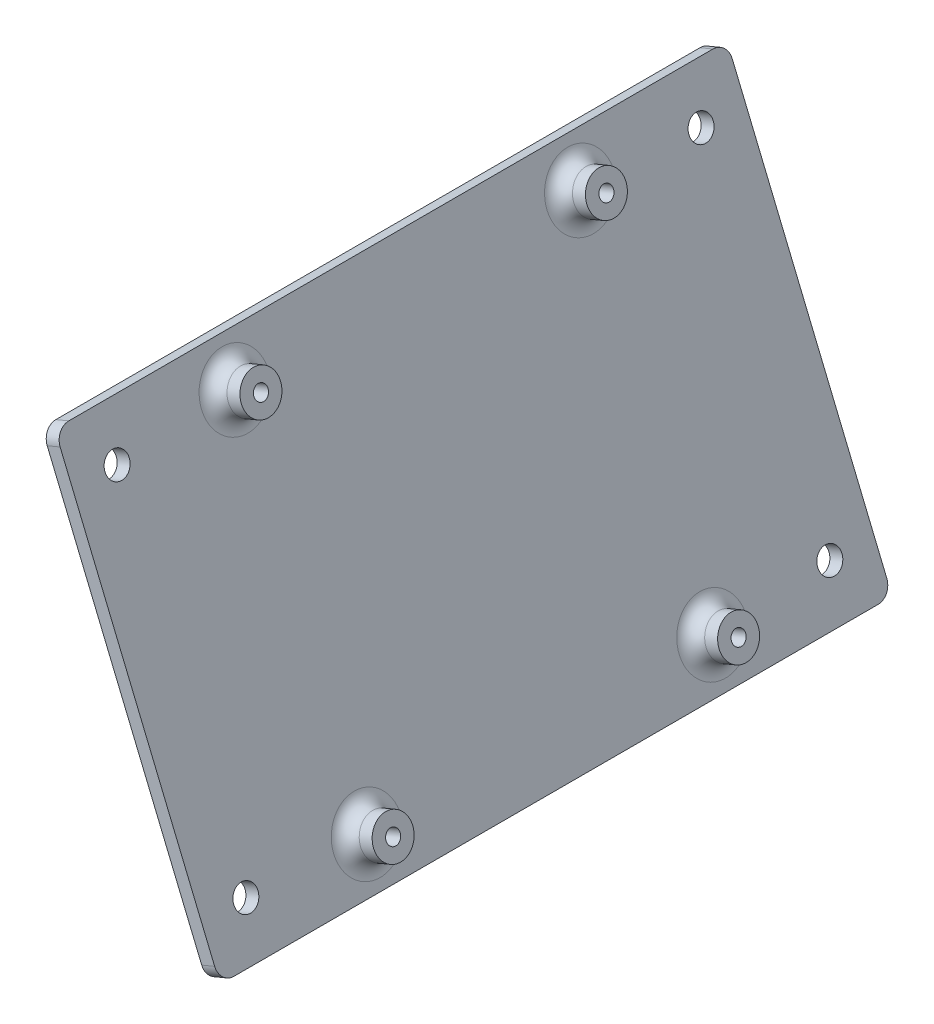
from build123d import *

# Parameters (mm, degrees)
SKETCH1_W           = 152.4
SKETCH1_H           = 97.79
BOSS_EXTRUDE1_DEPTH = 3.175
SKETCH2_R           = 4.445
BOSS_EXTRUDE2_DEPTH = 6.35
FILLET1_R           = 3.175
SKETCH4_R           = 1.6
CUT_EXTRUDE1_DEPTH  = 45.126339074
FILLET2_R           = 3.175
CUT_EXTRUDE2_DEPTH  = 38.776339074


with BuildPart() as part:
    # Sketch1 → Boss-Extrude1 (new body)
    with BuildSketch(Plane(origin=(-3845.744053595, -1594.742620069, 0), x_dir=(0, 0, -1), z_dir=(0.923728021, 0.383049008, 0))):
        with Locations((-2.512437172, -244.506793415)):
            Rectangle(SKETCH1_W, SKETCH1_H)
    extrude(amount=BOSS_EXTRUDE1_DEPTH)

    # Sketch2 → Boss-Extrude2 (add)
    with BuildSketch(Plane(origin=(-3842.811217127, -1593.526439469, 0), x_dir=(0, 0, -1), z_dir=(0.923728021, 0.383049008, 0))):
        with Locations((36.752562828, -283.626793415)):
            Circle(SKETCH2_R)
        with Locations((-41.577437172, -283.626793415)):
            Circle(SKETCH2_R)
        with Locations((-41.577437172, -205.386793415)):
            Circle(SKETCH2_R)
        with Locations((36.752562828, -205.386793415)):
            Circle(SKETCH2_R)
    extrude(amount=BOSS_EXTRUDE2_DEPTH)

    # Fillet1
    fillet1_edges = [part.edges().sort_by_distance(p)[0] for p in [
        (-3734.168255249, -1855.520456151, -32.307562828),
        (-3734.168255249, -1855.520456151, 46.022437172),
        (-3764.13800964, -1783.247975761, 46.022437172),
        (-3764.13800964, -1783.247975761, -32.307562828),
    ]]
    fillet(fillet1_edges, radius=FILLET1_R)

    # Sketch4 → Cut-Extrude1 (cut, through all)
    with BuildSketch(Plane(origin=(-3836.945544191, -1591.094078268, 0), x_dir=(0, 0, -1), z_dir=(0.923728021, 0.383049008, 0))):
        with Locations((36.752562828, -205.386793415)):
            Circle(SKETCH4_R)
        with Locations((-41.577437172, -205.386793415)):
            Circle(SKETCH4_R)
        with Locations((-41.577437172, -283.626793415)):
            Circle(SKETCH4_R)
        with Locations((36.752562828, -283.626793415)):
            Circle(SKETCH4_R)
    extrude(amount=-CUT_EXTRUDE1_DEPTH, mode=Mode.SUBTRACT)

    # Fillet2
    fillet2_edges = [part.edges().sort_by_distance(p)[0] for p in [
        (-3731.890369429, -1865.15798786, -73.687562828),
        (-3731.890369429, -1865.15798786, 78.712437172),
        (-3769.348731928, -1774.826624652, 78.712437172),
        (-3769.348731928, -1774.826624652, -73.687562828),
    ]]
    fillet(fillet2_edges, radius=FILLET2_R)

    # Sketch5 → Cut-Extrude2 (cut, through all)
    with BuildSketch(Plane(origin=(-3842.811217127, -1593.526439469, 0), x_dir=(0, 0, -1), z_dir=(0.923728021, 0.383049008, 0))):
        with BuildLine():
            ThreePointArc((65.787562828, -280.831265324), (63.687562828, -279.856793415), (61.587562828, -280.831265324))
            Line((61.587562828, -280.831265324), (61.587562828, -284.382321505))
            ThreePointArc((61.587562828, -284.382321505), (63.687562828, -285.356793415), (65.787562828, -284.382321505))
            Line((65.787562828, -284.382321505), (65.787562828, -280.831265324))
        make_face()
        with BuildLine():
            Line((61.587562828, -284.382321505), (61.587562828, -280.831265324))
            ThreePointArc((61.587562828, -280.831265324), (60.937562828, -282.606793415), (61.587562828, -284.382321505))
        make_face()
        with BuildLine():
            ThreePointArc((66.437562828, -282.606793415), (66.269955129, -281.661409895), (65.787562828, -280.831265324))
            Line((65.787562828, -280.831265324), (65.787562828, -284.382321505))
            ThreePointArc((65.787562828, -284.382321505), (66.269955129, -283.552176935), (66.437562828, -282.606793415))
        make_face()
        with BuildLine():
            ThreePointArc((65.787562828, -204.631265324), (63.687562828, -203.656793415), (61.587562828, -204.631265324))
            Line((61.587562828, -204.631265324), (61.587562828, -208.182321505))
            ThreePointArc((61.587562828, -208.182321505), (63.687562828, -209.156793415), (65.787562828, -208.182321505))
            Line((65.787562828, -208.182321505), (65.787562828, -204.631265324))
        make_face()
        with BuildLine():
            Line((61.587562828, -208.182321505), (61.587562828, -204.631265324))
            ThreePointArc((61.587562828, -204.631265324), (60.937562828, -206.406793415), (61.587562828, -208.182321505))
        make_face()
        with BuildLine():
            ThreePointArc((66.437562828, -206.406793415), (66.269955129, -205.461409895), (65.787562828, -204.631265324))
            Line((65.787562828, -204.631265324), (65.787562828, -208.182321505))
            ThreePointArc((65.787562828, -208.182321505), (66.269955129, -207.352176935), (66.437562828, -206.406793415))
        make_face()
        with BuildLine():
            Line((-70.812437172, -208.182321505), (-70.812437172, -204.631265324))
            ThreePointArc((-70.812437172, -204.631265324), (-71.462437172, -206.406793415), (-70.812437172, -208.182321505))
        make_face()
        with BuildLine():
            ThreePointArc((-66.612437172, -204.631265324), (-68.712437172, -203.656793415), (-70.812437172, -204.631265324))
            Line((-70.812437172, -204.631265324), (-70.812437172, -208.182321505))
            ThreePointArc((-70.812437172, -208.182321505), (-68.712437172, -209.156793415), (-66.612437172, -208.182321505))
            Line((-66.612437172, -208.182321505), (-66.612437172, -204.631265324))
        make_face()
        with BuildLine():
            ThreePointArc((-65.962437172, -206.406793415), (-66.130044871, -205.461409895), (-66.612437172, -204.631265324))
            Line((-66.612437172, -204.631265324), (-66.612437172, -208.182321505))
            ThreePointArc((-66.612437172, -208.182321505), (-66.130044871, -207.352176935), (-65.962437172, -206.406793415))
        make_face()
        with BuildLine():
            ThreePointArc((-66.612437172, -280.831265324), (-68.712437172, -279.856793415), (-70.812437172, -280.831265324))
            Line((-70.812437172, -280.831265324), (-70.812437172, -284.382321505))
            ThreePointArc((-70.812437172, -284.382321505), (-68.712437172, -285.356793415), (-66.612437172, -284.382321505))
            Line((-66.612437172, -284.382321505), (-66.612437172, -280.831265324))
        make_face()
        with BuildLine():
            ThreePointArc((-65.962437172, -282.606793415), (-66.130044871, -281.661409895), (-66.612437172, -280.831265324))
            Line((-66.612437172, -280.831265324), (-66.612437172, -284.382321505))
            ThreePointArc((-66.612437172, -284.382321505), (-66.130044871, -283.552176935), (-65.962437172, -282.606793415))
        make_face()
        with BuildLine():
            Line((-70.812437172, -284.382321505), (-70.812437172, -280.831265324))
            ThreePointArc((-70.812437172, -280.831265324), (-71.462437172, -282.606793415), (-70.812437172, -284.382321505))
        make_face()
    extrude(amount=-CUT_EXTRUDE2_DEPTH, mode=Mode.SUBTRACT)


solid = part.part
